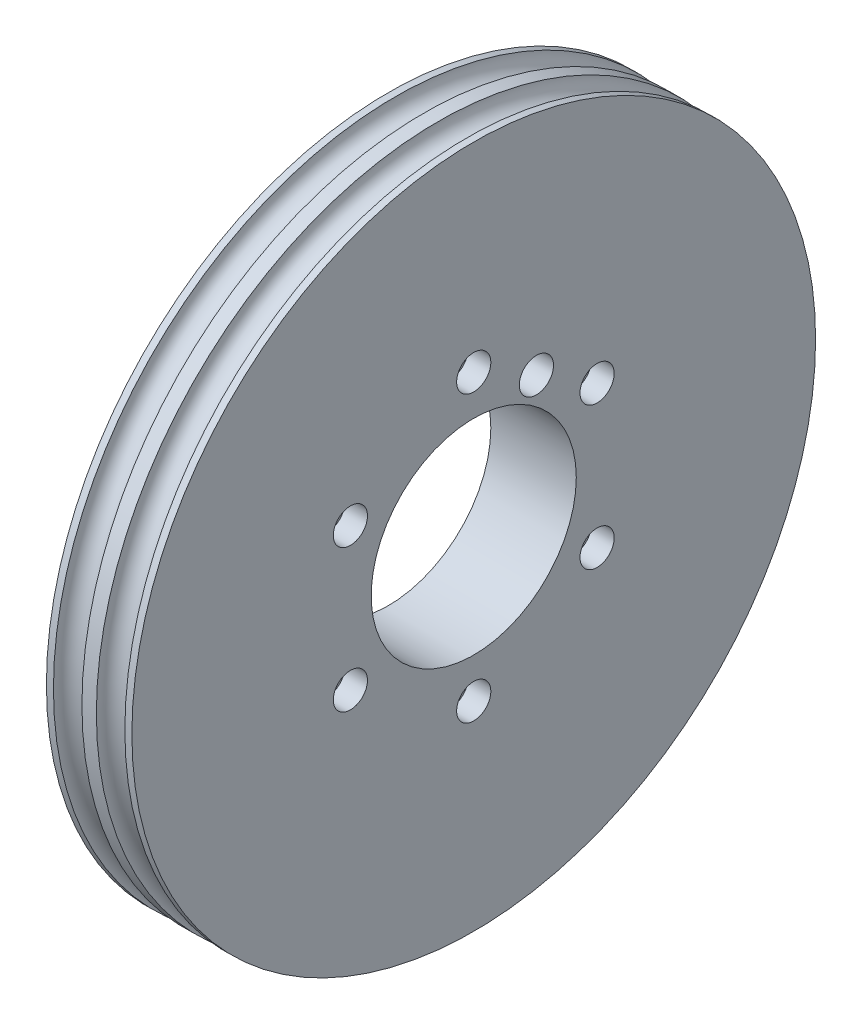
from build123d import *

# Parameters (mm, degrees)
SKETCH1_R           = 60
SKETCH1_R_2         = 18
BOSS_EXTRUDE1_DEPTH = 7.5
CUT_EXTRUDE2_REACH  = 17
SKETCH3_R           = 2
SKETCH4_R           = 33
SKETCH4_R_2         = 31.5
SKETCH4_R_3         = 30
CUT_EXTRUDE3_DEPTH  = 3
SKETCH5_R           = 2.5
SKETCH6_R           = 3
CUT_EXTRUDE4_DEPTH  = 4
CUT_EXTRUDE5_REACH  = 17
SKETCH7_R           = 3


with BuildPart() as part:
    # Sketch1 → Boss-Extrude1 (new body, symmetric)
    with BuildSketch(Plane(origin=(0, 0, 0), x_dir=(0, 0, -1), z_dir=(1, 0, 0))):
        Circle(SKETCH1_R)
        Circle(SKETCH1_R_2, mode=Mode.SUBTRACT)
    extrude(amount=BOSS_EXTRUDE1_DEPTH, both=True)

    # Sketch3 → Cut-Extrude2 (cut, up to next)
    with BuildSketch(Plane(origin=(7.5, 0, 0), x_dir=(0, 0, -1), z_dir=(1, 0, 0)), mode=Mode.PRIVATE) as cut_extrude2_sk1:
        with Locations((0, 25)):
            Circle(SKETCH3_R)
    cut_extrude2_tool1 = extrude(cut_extrude2_sk1.sketch, amount=-CUT_EXTRUDE2_REACH, mode=Mode.PRIVATE) & part.part
    add(cut_extrude2_tool1.solids().sort_by_distance((7.5, 25, 0))[0], mode=Mode.SUBTRACT)
    # Sketch3 → Cut-Extrude2 (cut, up to next)
    with BuildSketch(Plane(origin=(7.5, 0, 0), x_dir=(0, 0, -1), z_dir=(1, 0, 0)), mode=Mode.PRIVATE) as cut_extrude2_sk2:
        with Locations((21.650635095, 12.5)):
            Circle(SKETCH3_R)
    cut_extrude2_tool2 = extrude(cut_extrude2_sk2.sketch, amount=-CUT_EXTRUDE2_REACH, mode=Mode.PRIVATE) & part.part
    add(cut_extrude2_tool2.solids().sort_by_distance((7.5, 12.5, -21.650635))[0], mode=Mode.SUBTRACT)
    # Sketch3 → Cut-Extrude2 (cut, up to next)
    with BuildSketch(Plane(origin=(7.5, 0, 0), x_dir=(0, 0, -1), z_dir=(1, 0, 0)), mode=Mode.PRIVATE) as cut_extrude2_sk3:
        with Locations((21.650635095, -12.5)):
            Circle(SKETCH3_R)
    cut_extrude2_tool3 = extrude(cut_extrude2_sk3.sketch, amount=-CUT_EXTRUDE2_REACH, mode=Mode.PRIVATE) & part.part
    add(cut_extrude2_tool3.solids().sort_by_distance((7.5, -12.5, -21.650635))[0], mode=Mode.SUBTRACT)
    # Sketch3 → Cut-Extrude2 (cut, up to next)
    with BuildSketch(Plane(origin=(7.5, 0, 0), x_dir=(0, 0, -1), z_dir=(1, 0, 0)), mode=Mode.PRIVATE) as cut_extrude2_sk4:
        with Locations((0, -25)):
            Circle(SKETCH3_R)
    cut_extrude2_tool4 = extrude(cut_extrude2_sk4.sketch, amount=-CUT_EXTRUDE2_REACH, mode=Mode.PRIVATE) & part.part
    add(cut_extrude2_tool4.solids().sort_by_distance((7.5, -25, 0))[0], mode=Mode.SUBTRACT)
    # Sketch3 → Cut-Extrude2 (cut, up to next)
    with BuildSketch(Plane(origin=(7.5, 0, 0), x_dir=(0, 0, -1), z_dir=(1, 0, 0)), mode=Mode.PRIVATE) as cut_extrude2_sk5:
        with Locations((-21.650635095, -12.5)):
            Circle(SKETCH3_R)
    cut_extrude2_tool5 = extrude(cut_extrude2_sk5.sketch, amount=-CUT_EXTRUDE2_REACH, mode=Mode.PRIVATE) & part.part
    add(cut_extrude2_tool5.solids().sort_by_distance((7.5, -12.5, 21.650635))[0], mode=Mode.SUBTRACT)
    # Sketch3 → Cut-Extrude2 (cut, up to next)
    with BuildSketch(Plane(origin=(7.5, 0, 0), x_dir=(0, 0, -1), z_dir=(1, 0, 0)), mode=Mode.PRIVATE) as cut_extrude2_sk6:
        with Locations((-21.650635095, 12.5)):
            Circle(SKETCH3_R)
    cut_extrude2_tool6 = extrude(cut_extrude2_sk6.sketch, amount=-CUT_EXTRUDE2_REACH, mode=Mode.PRIVATE) & part.part
    add(cut_extrude2_tool6.solids().sort_by_distance((7.5, 12.5, 21.650635))[0], mode=Mode.SUBTRACT)

    # Sketch4 → Cut-Extrude3 (cut)
    with BuildSketch(Plane.ZY.offset(7.5)):
        Circle(SKETCH4_R)
        Circle(SKETCH4_R_2, mode=Mode.SUBTRACT)
        Circle(SKETCH4_R_2)
        Circle(SKETCH4_R_3, mode=Mode.SUBTRACT)
    extrude(amount=-CUT_EXTRUDE3_DEPTH, mode=Mode.SUBTRACT)

    # Sketch5 → Cut-Revolve2 (revolve, cut)
    with BuildSketch(Plane.XY):
        with Locations((3.766886577, 60.013835775)):
            Circle(SKETCH5_R)
        with Locations((-3.766886577, 60.013835775)):
            Circle(SKETCH5_R)
    revolve(axis=Axis((7.5, 0, 0), (-1, 0, 0)), mode=Mode.SUBTRACT)

    # Sketch6 → Cut-Extrude4 (cut)
    with BuildSketch(Plane(origin=(7.5, 0, 0), x_dir=(0, 0, -1), z_dir=(1, 0, 0))):
        with Locations((0, 25)):
            Circle(SKETCH6_R)
        with Locations((21.650635095, 12.5)):
            Circle(SKETCH6_R)
        with Locations((21.650635095, -12.5)):
            Circle(SKETCH6_R)
        with Locations((0, -25)):
            Circle(SKETCH6_R)
        with Locations((-21.650635095, -12.5)):
            Circle(SKETCH6_R)
        with Locations((-21.650635095, 12.5)):
            Circle(SKETCH6_R)
    extrude(amount=-CUT_EXTRUDE4_DEPTH, mode=Mode.SUBTRACT)

    # Sketch7 → Cut-Extrude5 (cut, up to next)
    with BuildSketch(Plane.ZY.offset(7.5), mode=Mode.PRIVATE) as cut_extrude5_sk1:
        with Locations((-11, 19.052558883)):
            Circle(SKETCH7_R)
    cut_extrude5_tool1 = extrude(cut_extrude5_sk1.sketch, amount=-CUT_EXTRUDE5_REACH, mode=Mode.PRIVATE) & part.part
    add(cut_extrude5_tool1.solids().sort_by_distance((-7.5, 19.052559, -11))[0], mode=Mode.SUBTRACT)


solid = part.part
